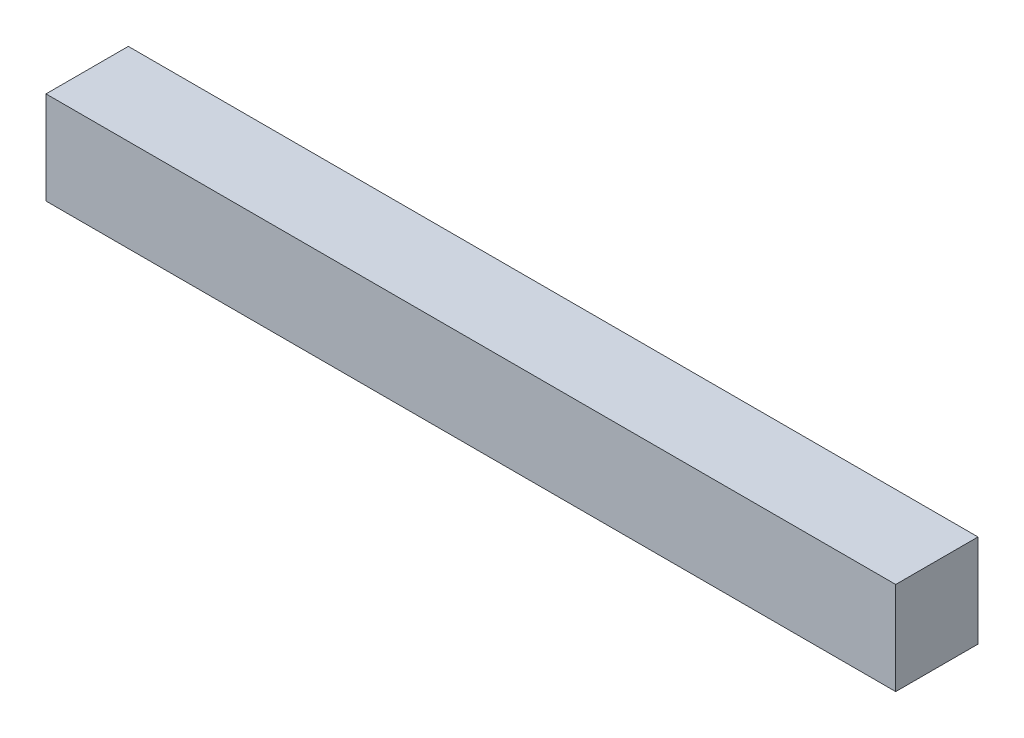
from build123d import *

# Parameters (mm, degrees)
SKETCH1_W      = 1032.475687356
SKETCH1_H      = 112.787010209
EXTRUDE1_DEPTH = 100


with BuildPart() as part:
    # Sketch1 → Extrude1 (new body)
    with BuildSketch(Plane.XY):
        with Locations((-12279.432907742, 4918.545621568)):
            Rectangle(SKETCH1_W, SKETCH1_H)
    extrude(amount=EXTRUDE1_DEPTH)


solid = part.part
